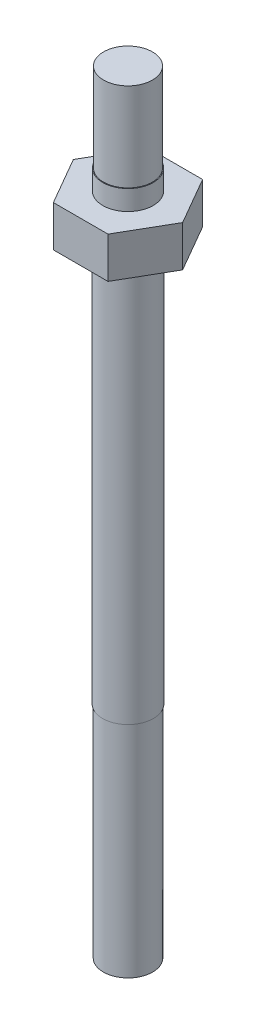
from build123d import *

# Parameters (mm, degrees)
SKETCH1_R           = 1.7145
BOSS_EXTRUDE1_DEPTH = 42.0878
BOSS_EXTRUDE2_DEPTH = 2.7686
SKETCH3_R           = 1.7018
BOSS_EXTRUDE3_DEPTH = 7.3152
SKETCH4_R           = 1.7018
SKETCH4_R_2         = 1.651
CUT_EXTRUDE1_DEPTH  = 5.969
SKETCH5_R           = 1.7145
SKETCH5_R_2         = 1.6637
CUT_EXTRUDE2_DEPTH  = 14.859


with BuildPart() as part:
    # Sketch1 → Boss-Extrude1 (new body)
    with BuildSketch(Plane(origin=(0, 0, 0), x_dir=(1, 0, 0), z_dir=(0, 1, 0))):
        with Locations(Location((0, 0, 0), (0, 0, 270))):  # turned: the seam where the file's is
            Circle(SKETCH1_R)
    extrude(amount=-BOSS_EXTRUDE1_DEPTH)

    # Sketch2 → Boss-Extrude2 (add)
    with BuildSketch(Plane(origin=(0, 0, 0), x_dir=(1, 0, 0), z_dir=(0, 1, 0))):
        Polygon((1.844793874, 3.195276719), (-1.844793874, 3.195276719), (-3.689587747, 0), (-1.844793874, -3.195276719), (1.844793874, -3.195276719), (3.689587747, 0), align=None)
    extrude(amount=BOSS_EXTRUDE2_DEPTH)

    # Sketch3 → Boss-Extrude3 (add)
    with BuildSketch(Plane(origin=(0, 2.7686, 0), x_dir=(1, 0, 0), z_dir=(0, 1, 0))):
        with Locations(Location((0, 0, 0), (0, 0, 270))):  # turned: the seam where the file's is
            Circle(SKETCH3_R)
    extrude(amount=BOSS_EXTRUDE3_DEPTH)

    # Sketch4 → Cut-Extrude1 (cut)
    with BuildSketch(Plane(origin=(0, 10.0838, 0), x_dir=(1, 0, 0), z_dir=(0, 1, 0))):
        with Locations(Location((0, 0, 0), (0, 0, 270))):  # turned: the seam where the file's is
            Circle(SKETCH4_R)
        with Locations(Location((0, 0, 0), (0, 0, 270))):  # turned: the seam where the file's is
            Circle(SKETCH4_R_2, mode=Mode.SUBTRACT)
    extrude(amount=-CUT_EXTRUDE1_DEPTH, mode=Mode.SUBTRACT)

    # Sketch5 → Cut-Extrude2 (cut)
    with BuildSketch(Plane.XZ.offset(42.0878)):
        with Locations(Location((0, 0, 0), (0, 0, 90))):  # turned: the seam where the file's is
            Circle(SKETCH5_R)
        with Locations(Location((0, 0, 0), (0, 0, 270))):  # turned: the seam where the file's is
            Circle(SKETCH5_R_2, mode=Mode.SUBTRACT)
    extrude(amount=-CUT_EXTRUDE2_DEPTH, mode=Mode.SUBTRACT)


solid = part.part
